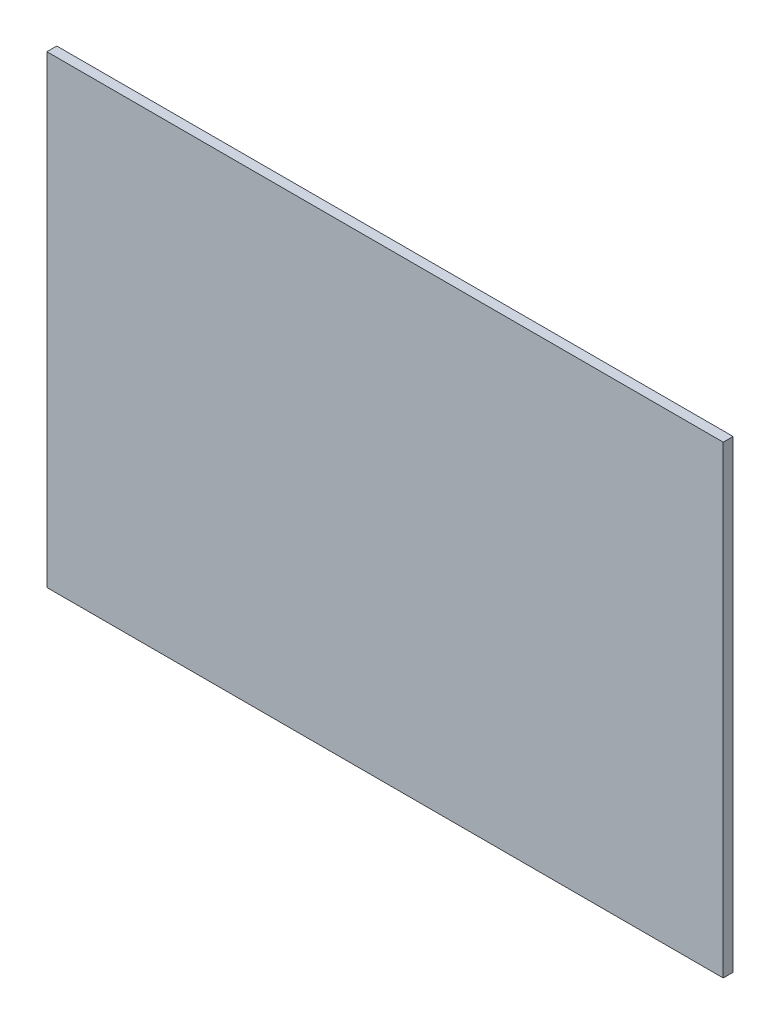
from build123d import *

# Parameters (mm, degrees)
SKETCH1_W           = 274
SKETCH1_H           = 188
BOSS_EXTRUDE1_DEPTH = 4


with BuildPart() as part:
    # Sketch1 → Boss-Extrude1 (new body)
    with BuildSketch(Plane.XY):
        with Locations((-1.214285714, 10.196428571)):
            Rectangle(SKETCH1_W, SKETCH1_H)
    extrude(amount=BOSS_EXTRUDE1_DEPTH)


solid = part.part
